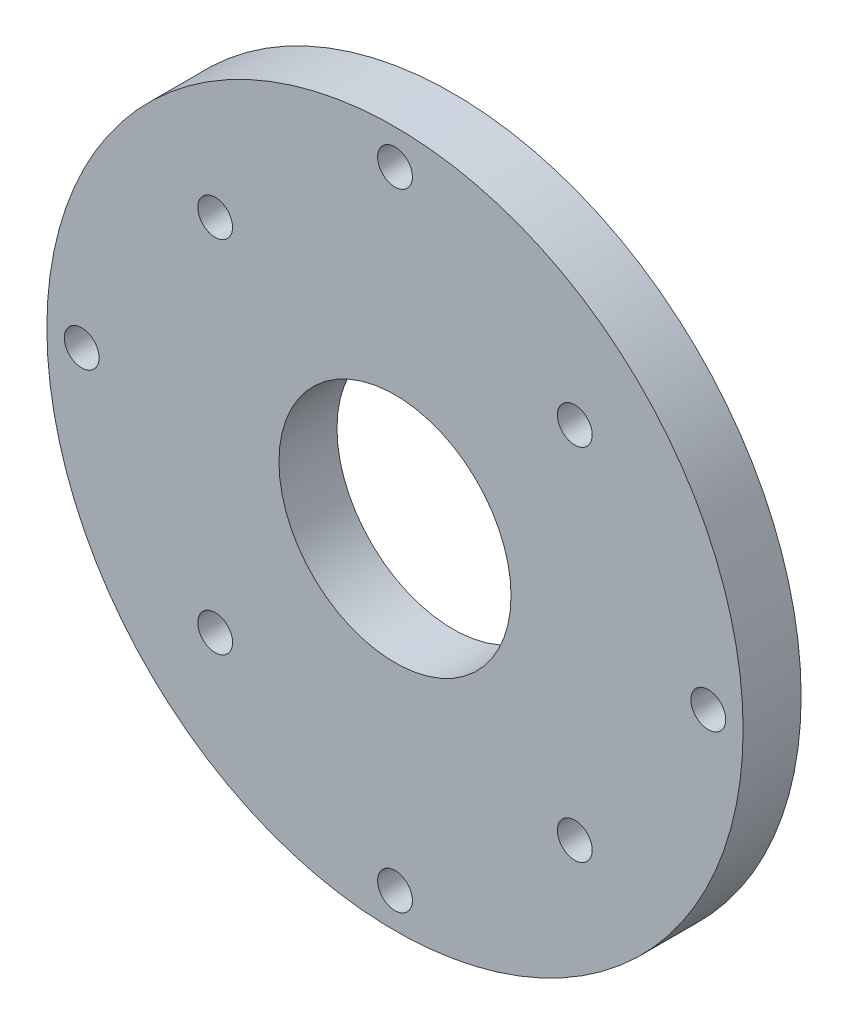
from build123d import *

# Parameters (mm, degrees)
SKETCH25_R          = 30
SKETCH25_R_2        = 1.5
BOSS_EXTRUDE1_DEPTH = 5
SKETCH26_R          = 10
CUT_EXTRUDE1_DEPTH  = 5


with BuildPart() as part:
    # Sketch25 → Boss-Extrude1 (new body)
    with BuildSketch(Plane.XY):
        Circle(SKETCH25_R)
        with Locations((15.495, 15.495)):
            Circle(SKETCH25_R_2, mode=Mode.SUBTRACT)
        with Locations((-15.495, 15.495)):
            Circle(SKETCH25_R_2, mode=Mode.SUBTRACT)
        with Locations((-15.495, -15.495)):
            Circle(SKETCH25_R_2, mode=Mode.SUBTRACT)
        with Locations((15.495, -15.495)):
            Circle(SKETCH25_R_2, mode=Mode.SUBTRACT)
        with Locations((0, 27)):
            Circle(SKETCH25_R_2, mode=Mode.SUBTRACT)
        with Locations((27, 0)):
            Circle(SKETCH25_R_2, mode=Mode.SUBTRACT)
        with Locations((0, -27)):
            Circle(SKETCH25_R_2, mode=Mode.SUBTRACT)
        with Locations((-27, 0)):
            Circle(SKETCH25_R_2, mode=Mode.SUBTRACT)
    extrude(amount=BOSS_EXTRUDE1_DEPTH)

    # Sketch26 → Cut-Extrude1 (cut)
    with BuildSketch(Plane.XY.offset(5)):
        Circle(SKETCH26_R)
        with Locations((-130.084851818, -8.286873835)):
            Circle(SKETCH26_R)
    extrude(amount=-CUT_EXTRUDE1_DEPTH, mode=Mode.SUBTRACT)


solid = part.part
